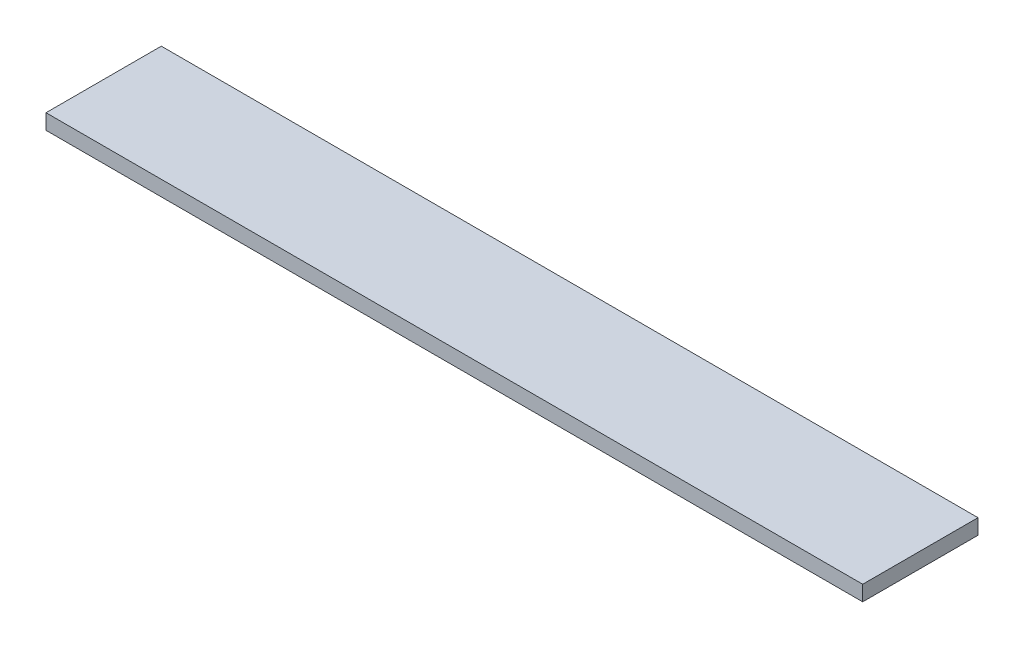
from build123d import *

# Parameters (mm, degrees)
SKETCH1_W           = 85
SKETCH1_H           = 12
BOSS_EXTRUDE1_DEPTH = 1.5875


with BuildPart() as part:
    # Sketch1 → Boss-Extrude1 (new body)
    with BuildSketch(Plane(origin=(0, 0, 0), x_dir=(1, 0, 0), z_dir=(0, 1, 0))):
        Rectangle(SKETCH1_W, SKETCH1_H)
    extrude(amount=BOSS_EXTRUDE1_DEPTH)


solid = part.part
